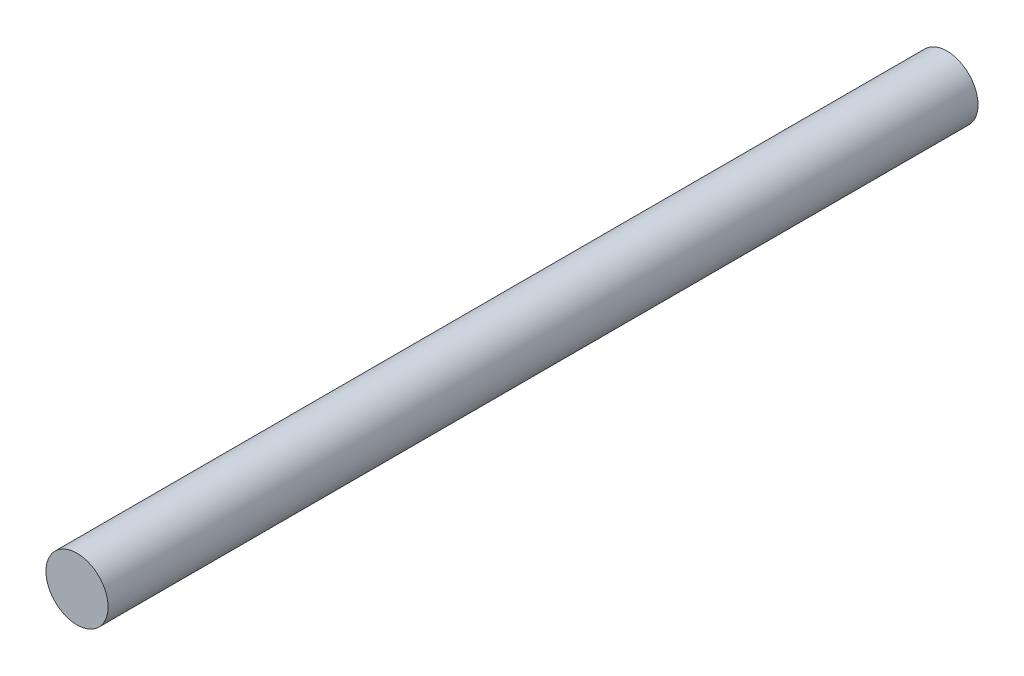
from build123d import *

# Parameters (mm, degrees)
SKETCH1_R           = 12.7
BOSS_EXTRUDE1_DEPTH = 355.6


with BuildPart() as part:
    # Sketch1 → Boss-Extrude1 (new body)
    with BuildSketch(Plane.XY):
        Circle(SKETCH1_R)
    extrude(amount=BOSS_EXTRUDE1_DEPTH)


solid = part.part
